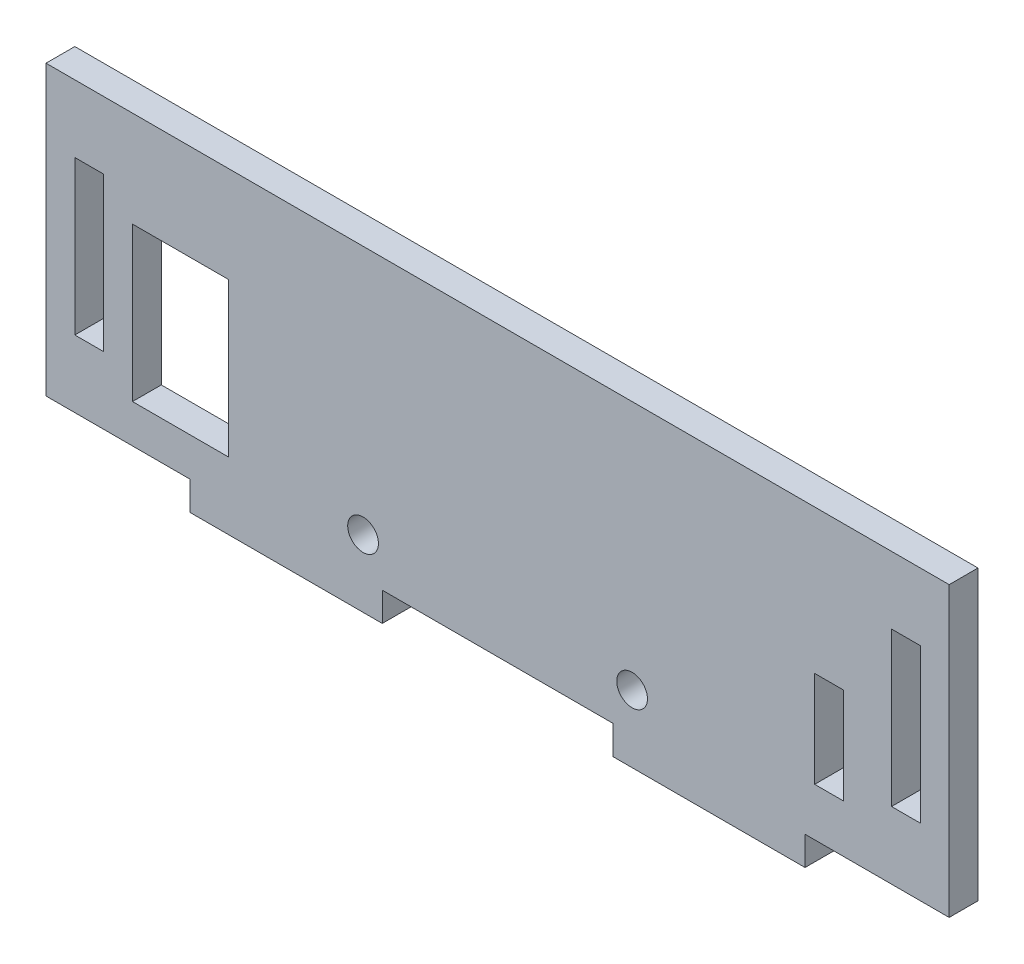
from build123d import *

# Parameters (mm, degrees)
SKETCH_1_R      = 1.6
SKETCH_1_W      = 3
SKETCH_1_H      = 10
EXTRUDE_1_DEPTH = 3


with BuildPart() as part:
    # 草图1 → 凸台-拉伸1 (new body)
    with BuildSketch(Plane.XY):
        Polygon((32, 0), (44, 0), (56, 0), (56, -3), (76, -3), (76, 0), (88, 0), (91, 0), (91, 30), (88, 30), (0, 30), (-3, 30), (-3, 0), (0, 0), (12, 0), (12, -3), (32, -3), align=None)
        with Locations((30, 4)):
            Circle(SKETCH_1_R, mode=Mode.SUBTRACT)
        Polygon((6, 4), (6, 7), (6, 20), (11, 20), (16, 20), (16, 4), (11, 4), align=None, mode=Mode.SUBTRACT)
        with BuildLine():
            ThreePointArc((59.6, 4), (58, 2.4), (56.4, 4))
            ThreePointArc((56.4, 4), (58, 5.6), (59.6, 4))
        make_face(mode=Mode.SUBTRACT)
        with Locations((78.5, 10)):
            Rectangle(SKETCH_1_W, SKETCH_1_H, mode=Mode.SUBTRACT)
        Polygon((0, 15), (0, 23), (3, 23), (3, 15), (3, 7), (0, 7), align=None, mode=Mode.SUBTRACT)
        Polygon((85, 23), (88, 23), (88, 15), (88, 7), (85, 7), (85, 15), align=None, mode=Mode.SUBTRACT)
    extrude(amount=EXTRUDE_1_DEPTH)


solid = part.part
